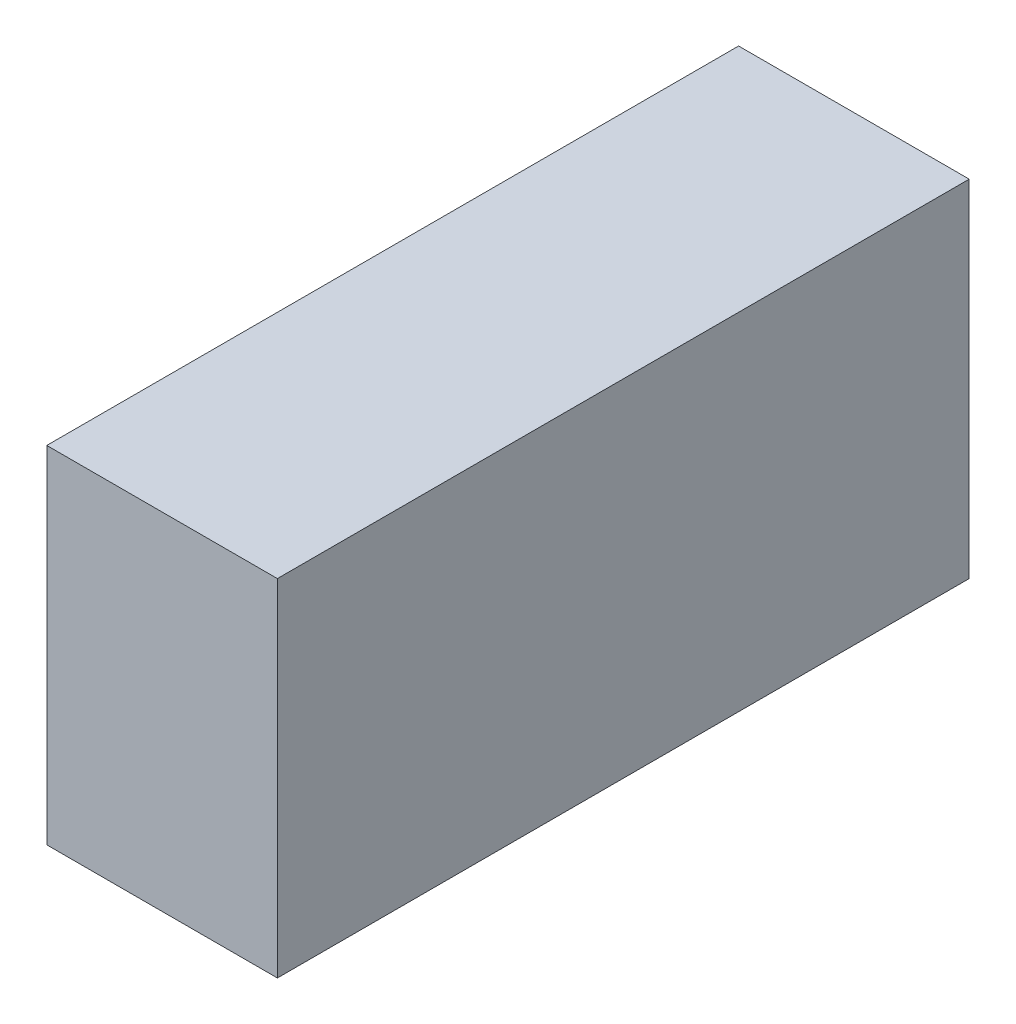
from build123d import *

# Parameters (mm, degrees)
SKETCH1_W           = 40
SKETCH1_H           = 60
BOSS_EXTRUDE1_DEPTH = 60


with BuildPart() as part:
    # Sketch1 → Boss-Extrude1 (new body, symmetric)
    with BuildSketch(Plane.XY):
        with Locations((0, 30)):
            Rectangle(SKETCH1_W, SKETCH1_H)
    extrude(amount=BOSS_EXTRUDE1_DEPTH, both=True)


solid = part.part
